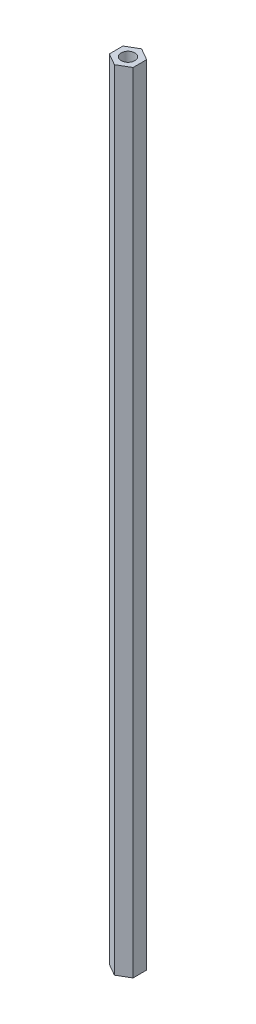
from build123d import *

# Parameters (mm, degrees)
ESQUISSE1_R      = 2.5
EXTRUSION1_DEPTH = 289


with BuildPart() as part:
    # Esquisse1 → Extrusion1 (new body)
    with BuildSketch(Plane(origin=(0, 0, 0), x_dir=(1, 0, 0), z_dir=(0, 1, 0))):
        Polygon((0, 5), (-4.330127019, 2.5), (-4.330127019, -2.5), (0, -5), (4.330127019, -2.5), (4.330127019, 2.5), align=None)
        Circle(ESQUISSE1_R, mode=Mode.SUBTRACT)
    extrude(amount=EXTRUSION1_DEPTH)


solid = part.part
